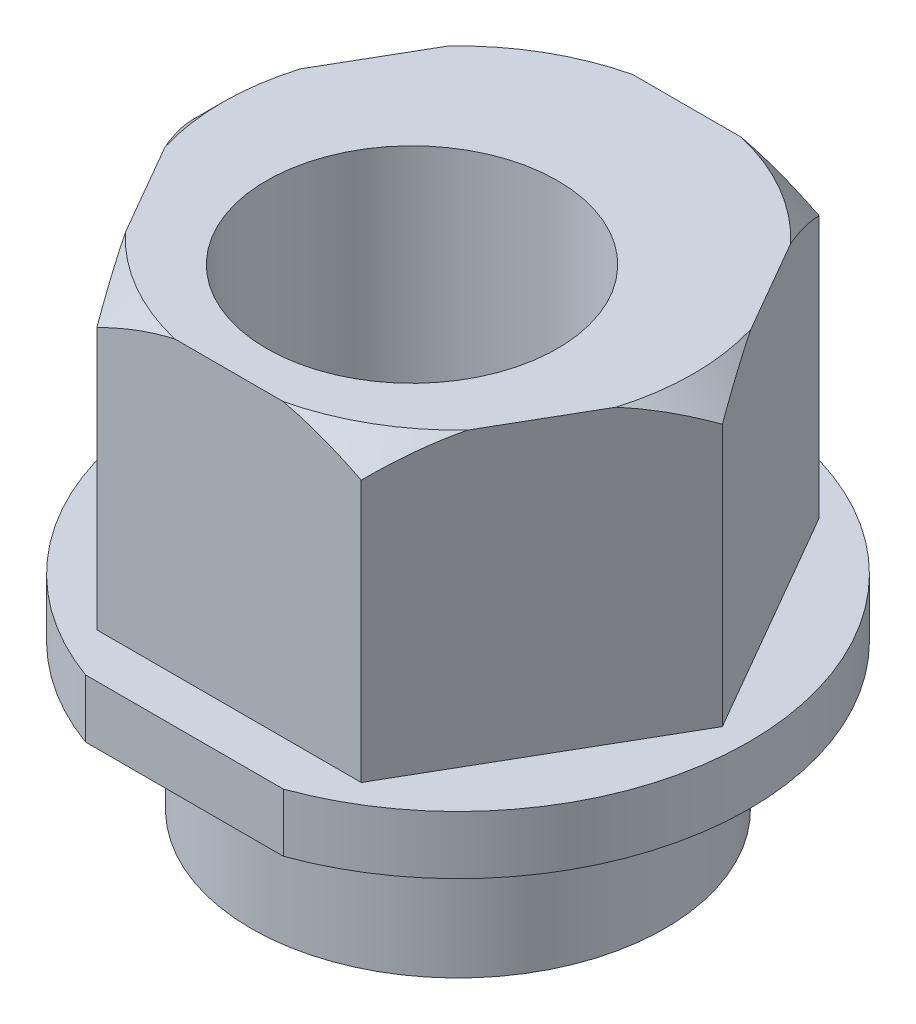
from build123d import *

# Parameters (mm, degrees)
BOSS_EXTRUDE1_DEPTH = 5
SKETCH2_R           = 5
BOSS_EXTRUDE2_DEPTH = 1
SKETCH3_R           = 3.555
BOSS_EXTRUDE3_DEPTH = 2.5
SKETCH4_R           = 2.5
CUT_EXTRUDE1_DEPTH  = 9.5
CUT_EXTRUDE2_DEPTH  = 4.5


with BuildPart() as part:
    # Sketch1 → Boss-Extrude1 (new body)
    with BuildSketch(Plane(origin=(0, 0, 0), x_dir=(1, 0, 0), z_dir=(0, 1, 0))):
        Polygon((4.543746619, 0), (2.271873309, 3.935), (-2.271873309, 3.935), (-4.543746619, 0), (-2.271873309, -3.935), (2.271873309, -3.935), align=None)
    extrude(amount=BOSS_EXTRUDE1_DEPTH)

    # Sketch2 → Boss-Extrude2 (add)
    with BuildSketch(Plane(origin=(0, 0, 0), x_dir=(1, 0, 0), z_dir=(0, 1, 0))):
        Circle(SKETCH2_R)
    extrude(amount=-BOSS_EXTRUDE2_DEPTH)

    # Sketch3 → Boss-Extrude3 (add)
    with BuildSketch(Plane.XZ.offset(1)):
        Circle(SKETCH3_R)
    extrude(amount=BOSS_EXTRUDE3_DEPTH)

    # Sketch4 → Cut-Extrude1 (cut, through all)
    with BuildSketch(Plane(origin=(0, 5, 0), x_dir=(1, 0, 0), z_dir=(0, 1, 0))):
        with Locations((0, -0.79)):
            Circle(SKETCH4_R)
    extrude(amount=-CUT_EXTRUDE1_DEPTH, mode=Mode.SUBTRACT)

    # Sketch5 → Cut-Extrude2 (cut, through all)
    with BuildSketch(Plane(origin=(0, 0, 0), x_dir=(1, 0, 0), z_dir=(0, 1, 0))):
        with BuildLine():
            Line((-1.7, -4.702127178), (1.7, -4.702127178))
            ThreePointArc((1.7, -4.702127178), (0, -5), (-1.7, -4.702127178))
        make_face()
    extrude(amount=-CUT_EXTRUDE2_DEPTH, mode=Mode.SUBTRACT)

    # Sketch6 → Cut-Revolve1 (revolve, cut)
    with BuildSketch(Plane.XY):
        Polygon((4.043746619, 5), (4.543746619, 5), (4.543746619, 4.5), align=None)
    revolve(axis=Axis((0, 0, 0), (0, 1, 0)), mode=Mode.SUBTRACT)


solid = part.part
